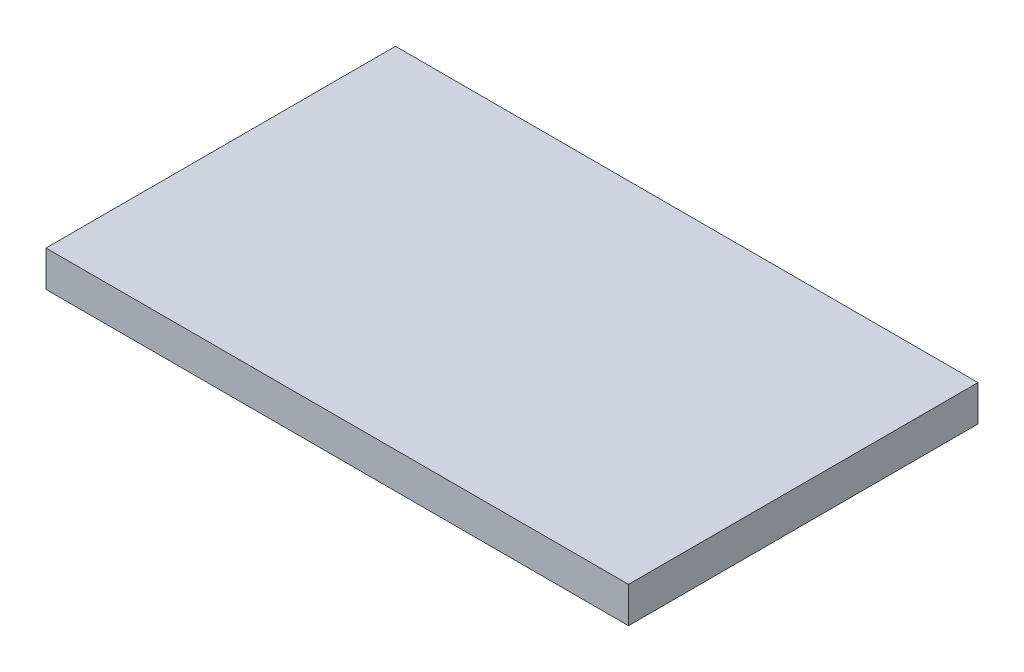
from build123d import *

# Parameters (mm, degrees)
ESBO_O1_W                = 32.5
ESBO_O1_H                = 19.5
RESSALTO_EXTRUS_O1_DEPTH = 2


with BuildPart() as part:
    # Esboço1 → Ressalto-extrusão1 (new body)
    with BuildSketch(Plane(origin=(0, 0, 0), x_dir=(1, 0, 0), z_dir=(0, 1, 0))):
        Rectangle(ESBO_O1_W, ESBO_O1_H)
    extrude(amount=RESSALTO_EXTRUS_O1_DEPTH)


solid = part.part
